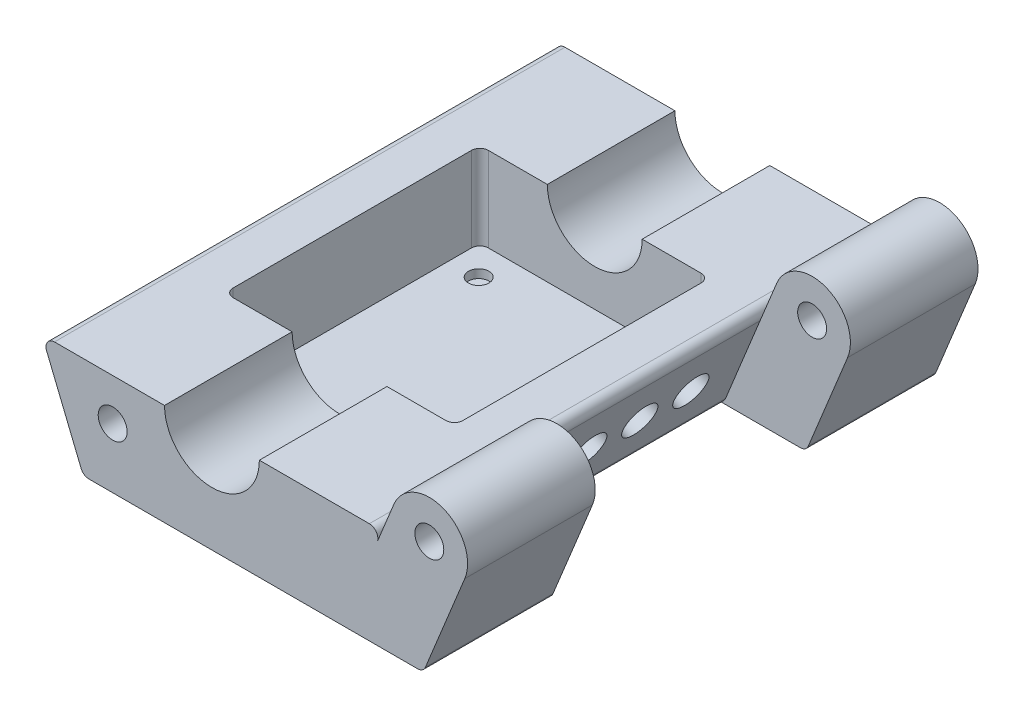
from build123d import *

# Parameters (mm, degrees)
BOSS_EXTRUDE3_DEPTH      = 30
BOSS_EXTRUDE3_DEPTH_BACK = 30
CUT_EXTRUDE1_DEPTH       = 9.93575
SKETCH1_R                = 1.205
CUT_EXTRUDE2_DEPTH       = 1
CUT_EXTRUDE3_REACH       = 38.571
SKETCH9_R                = 2
BOSS_EXTRUDE5_START      = -30
SKETCH20_R               = 1.7
BOSS_EXTRUDE5_DEPTH      = 15
BOSS_EXTRUDE6_START      = 30
SKETCH20_2_R             = 1.7
BOSS_EXTRUDE6_DEPTH      = 15
CUT_EXTRUDE6_START       = -30
SKETCH22_R               = 1.7
CUT_EXTRUDE6_DEPTH       = 10
CUT_EXTRUDE6_DEPTH_BACK  = 1
CUT_EXTRUDE7_START       = 30
SKETCH22_2_R             = 1.7
CUT_EXTRUDE7_DEPTH       = 10
CUT_EXTRUDE7_DEPTH_BACK  = 10


with BuildPart() as part:
    # Sketch5 → Boss-Extrude3 (new body, two sides)
    with BuildSketch(Plane.XY) as boss_extrude3_sk:
        with BuildLine():
            Line((-5.575, 9.935749893), (-18.505577921, 9.935749893))
            ThreePointArc((-18.505577921, 9.935749893), (-19.335599809, 9.493480712), (-19.431435495, 8.557877225))
            Line((-19.431435495, 8.557877225), (-15.376331952, -1.377872669))
            ThreePointArc((-15.376331952, -1.377872669), (-15.008205197, -1.830021888), (-14.450474378, -2))
            Line((-14.450474378, -2), (14.450474378, -2))
            ThreePointArc((14.450474378, -2), (15.008205197, -1.830021888), (15.376331952, -1.377872669))
            Line((15.376331952, -1.377872669), (19.431435495, 8.557877225))
            ThreePointArc((19.431435495, 8.557877225), (19.335599809, 9.493480712), (18.505577921, 9.935749893))
            Line((18.505577921, 9.935749893), (5.575, 9.935749893))
            ThreePointArc((5.575, 9.935749893), (0, 4.360749893), (-5.575, 9.935749893))
        make_face()
    extrude(amount=BOSS_EXTRUDE3_DEPTH)
    extrude(boss_extrude3_sk.sketch, amount=-BOSS_EXTRUDE3_DEPTH_BACK)

    # Sketch8 → Cut-Extrude1 (cut)
    with BuildSketch(Plane(origin=(0, 0, 0), x_dir=(1, 0, 0), z_dir=(0, 1, 0))):
        with BuildLine():
            Line((-12.5, 15), (12.5, 15))
            ThreePointArc((12.5, 15), (13.207106781, 14.707106781), (13.5, 14))
            Line((13.5, 14), (13.5, -14))
            ThreePointArc((13.5, -14), (13.207106781, -14.707106781), (12.5, -15))
            Line((12.5, -15), (-12.5, -15))
            ThreePointArc((-12.5, -15), (-13.207106781, -14.707106781), (-13.5, -14))
            Line((-13.5, -14), (-13.5, 14))
            ThreePointArc((-13.5, 14), (-13.207106781, 14.707106781), (-12.5, 15))
        make_face()
    extrude(amount=CUT_EXTRUDE1_DEPTH, mode=Mode.SUBTRACT)

    # Sketch1 → Cut-Extrude2 (cut)
    with BuildSketch(Plane(origin=(0, 0, 0), x_dir=(1, 0, 0), z_dir=(0, 1, 0))):
        with Locations((-10.105, 11.46)):
            Circle(SKETCH1_R)
        with Locations((-10.105, -11.46)):
            Circle(SKETCH1_R)
        with Locations((10.026555832, -11.46)):
            Circle(SKETCH1_R)
        with Locations((10.105, 11.46)):
            Circle(SKETCH1_R)
    extrude(amount=-CUT_EXTRUDE2_DEPTH, mode=Mode.SUBTRACT)

    # Cut-Extrude3: up to this face of the body (flat: up to its plane)
    cut_extrude3_end = Plane(part.part.faces().sort_by_distance((13.5, 4.967875, 0))[0])
    # Sketch9 → Cut-Extrude3 (cut, up to the picked face)
    with BuildSketch(Plane(origin=(13.662837448, -5.576249517, 0), x_dir=(0, 0, -1), z_dir=(0.925857573, -0.377872669, 0)), mode=Mode.PRIVATE) as cut_extrude3_sk1:
        with Locations((-9, 9.618413932)):
            Circle(SKETCH9_R)
    cut_extrude3_tool1 = split(extrude(cut_extrude3_sk1.sketch, amount=-CUT_EXTRUDE3_REACH, mode=Mode.PRIVATE), bisect_by=cut_extrude3_end, keep=Keep.BOTH, mode=Mode.PRIVATE)
    add(cut_extrude3_tool1.solids().sort_by_distance((17.297373, 3.329032, 9))[0], mode=Mode.SUBTRACT)
    # Sketch9 → Cut-Extrude3 (cut, up to the picked face)
    with BuildSketch(Plane(origin=(13.662837448, -5.576249517, 0), x_dir=(0, 0, -1), z_dir=(0.925857573, -0.377872669, 0)), mode=Mode.PRIVATE) as cut_extrude3_sk2:
        with Locations((-3, 9.618413932)):
            Circle(SKETCH9_R)
    cut_extrude3_tool2 = split(extrude(cut_extrude3_sk2.sketch, amount=-CUT_EXTRUDE3_REACH, mode=Mode.PRIVATE), bisect_by=cut_extrude3_end, keep=Keep.BOTH, mode=Mode.PRIVATE)
    add(cut_extrude3_tool2.solids().sort_by_distance((17.297373, 3.329032, 3))[0], mode=Mode.SUBTRACT)
    # Sketch9 → Cut-Extrude3 (cut, up to the picked face)
    with BuildSketch(Plane(origin=(13.662837448, -5.576249517, 0), x_dir=(0, 0, -1), z_dir=(0.925857573, -0.377872669, 0)), mode=Mode.PRIVATE) as cut_extrude3_sk3:
        with Locations((3, 9.618413932)):
            Circle(SKETCH9_R)
    cut_extrude3_tool3 = split(extrude(cut_extrude3_sk3.sketch, amount=-CUT_EXTRUDE3_REACH, mode=Mode.PRIVATE), bisect_by=cut_extrude3_end, keep=Keep.BOTH, mode=Mode.PRIVATE)
    add(cut_extrude3_tool3.solids().sort_by_distance((17.297373, 3.329032, -3))[0], mode=Mode.SUBTRACT)
    # Sketch9 → Cut-Extrude3 (cut, up to the picked face)
    with BuildSketch(Plane(origin=(13.662837448, -5.576249517, 0), x_dir=(0, 0, -1), z_dir=(0.925857573, -0.377872669, 0)), mode=Mode.PRIVATE) as cut_extrude3_sk4:
        with Locations((9, 9.618413932)):
            Circle(SKETCH9_R)
    cut_extrude3_tool4 = split(extrude(cut_extrude3_sk4.sketch, amount=-CUT_EXTRUDE3_REACH, mode=Mode.PRIVATE), bisect_by=cut_extrude3_end, keep=Keep.BOTH, mode=Mode.PRIVATE)
    add(cut_extrude3_tool4.solids().sort_by_distance((17.297373, 3.329032, -9))[0], mode=Mode.SUBTRACT)

    # Sketch20 → Boss-Extrude5 (add)
    with BuildSketch(Plane.XY.offset(BOSS_EXTRUDE5_START)):
        with BuildLine():
            Line((19.431435495, 8.557877225), (15.376331952, -1.377872669))
            ThreePointArc((15.376331952, -1.377872669), (15.008205197, -1.830021888), (14.450474378, -2))
            Line((14.450474378, -2), (24.171191968, -2))
            ThreePointArc((24.171191968, -2), (24.728922787, -1.830021888), (25.097049542, -1.377872669))
            Line((25.097049542, -1.377872669), (29.71812802, 9.944619967))
            ThreePointArc((29.71812802, 9.944619967), (27.252195948, 15.811406056), (21.385409859, 13.345473984))
            Line((21.385409859, 13.345473984), (19.431435495, 8.557877225))
        make_face()
        with Locations((25.55176894, 11.645046975)):
            Circle(SKETCH20_R, mode=Mode.SUBTRACT)
    extrude(amount=BOSS_EXTRUDE5_DEPTH)

    # Sketch20_2 → Boss-Extrude6 (add)
    with BuildSketch(Plane.XY.offset(BOSS_EXTRUDE6_START)):
        with BuildLine():
            Line((19.431435495, 8.557877225), (15.376331952, -1.377872669))
            ThreePointArc((15.376331952, -1.377872669), (15.008205197, -1.830021888), (14.450474378, -2))
            Line((14.450474378, -2), (24.171191968, -2))
            ThreePointArc((24.171191968, -2), (24.728922787, -1.830021888), (25.097049542, -1.377872669))
            Line((25.097049542, -1.377872669), (29.71812802, 9.944619967))
            ThreePointArc((29.71812802, 9.944619967), (27.252195948, 15.811406056), (21.385409859, 13.345473984))
            Line((21.385409859, 13.345473984), (19.431435495, 8.557877225))
        make_face()
        with Locations((25.55176894, 11.645046975)):
            Circle(SKETCH20_2_R, mode=Mode.SUBTRACT)
    extrude(amount=-BOSS_EXTRUDE6_DEPTH)

    # Sketch22 → Cut-Extrude6 (cut, two sides)
    with BuildSketch(Plane.XY.offset(CUT_EXTRUDE6_START)) as cut_extrude6_sk:
        with Locations((-11.667770039, 5.055979667)):
            Circle(SKETCH22_R)
    extrude(amount=CUT_EXTRUDE6_DEPTH, mode=Mode.SUBTRACT)
    extrude(cut_extrude6_sk.sketch, amount=-CUT_EXTRUDE6_DEPTH_BACK, mode=Mode.SUBTRACT)

    # Sketch22_2 → Cut-Extrude7 (cut, two sides)
    with BuildSketch(Plane.XY.offset(CUT_EXTRUDE7_START)) as cut_extrude7_sk:
        with Locations((-11.667770039, 5.055979667)):
            Circle(SKETCH22_2_R)
    extrude(amount=CUT_EXTRUDE7_DEPTH, mode=Mode.SUBTRACT)
    extrude(cut_extrude7_sk.sketch, amount=-CUT_EXTRUDE7_DEPTH_BACK, mode=Mode.SUBTRACT)


solid = part.part
